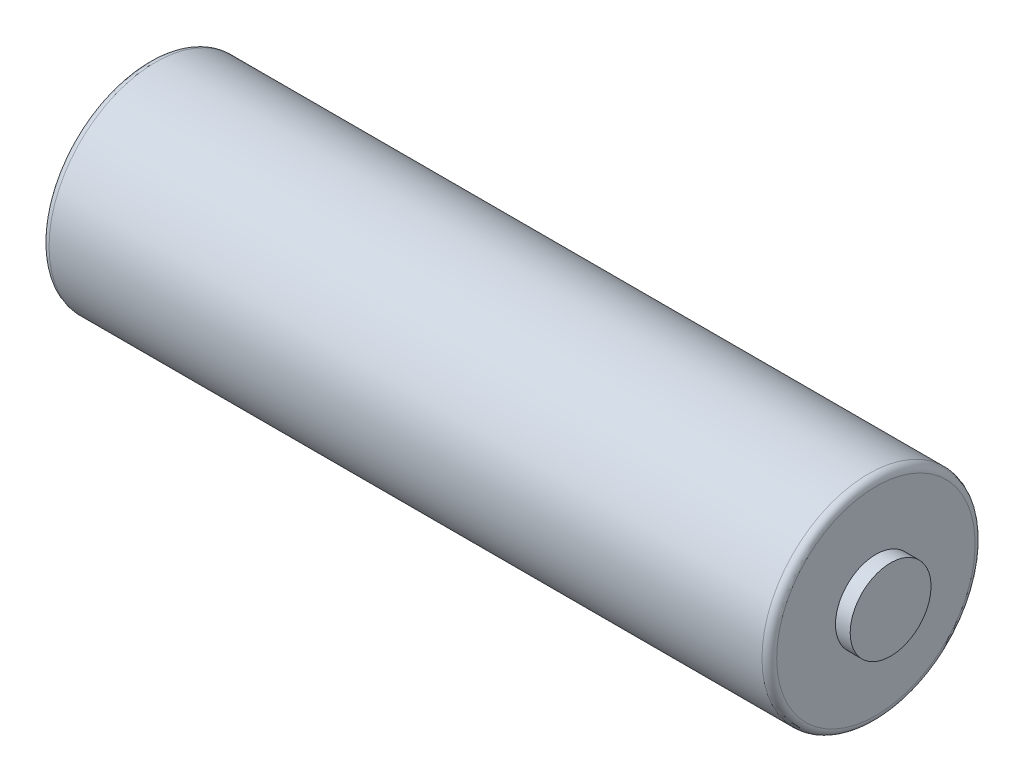
from build123d import *

# Parameters (mm, degrees)
FILLET1_R = 0.5


with BuildPart() as part:
    # Sketch2 → Revolve1 (revolve)
    with BuildSketch(Plane.XY):
        Polygon((0, 0), (0, 7.25), (49.5, 7.25), (49.5, 2.75), (50.5, 2.75), (50.5, 0), align=None)
    revolve(axis=Axis((0, 0, 0), (1, 0, 0)))

    # Fillet1
    fillet1_edges = [part.edges().sort_by_distance(p)[0] for p in [
        (49.5, -7.25, 0),
        (0, -7.25, 0),
    ]]
    fillet(fillet1_edges, radius=FILLET1_R)


solid = part.part
